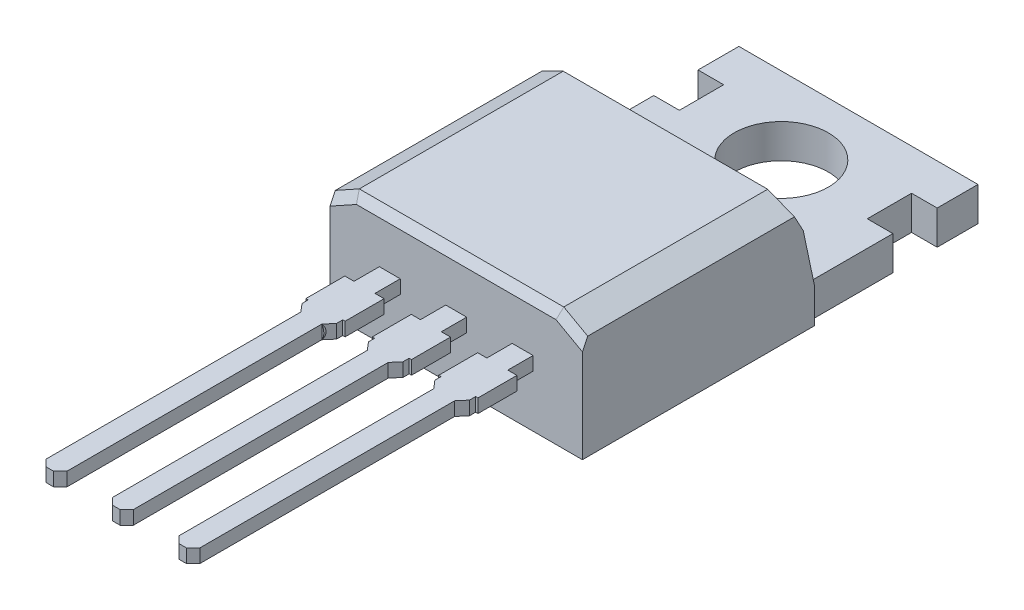
from build123d import *
from OCP.BRepFilletAPI import BRepFilletAPI_MakeChamfer

# Parameters (mm, degrees)
EXTRUDE1_DEPTH      = 4.826
EXTRUDE1_DEPTH_BACK = 4.826
SKETCH10_R          = 1.8
SKETCH10_W          = 1.233836604
SKETCH10_H          = 1.6931216
EXTRUDE5_DEPTH      = 16.428369203
SKETCH6_W           = 0.8
SKETCH6_H           = 0.52
EXTRUDE6_DEPTH      = 13
EXTRUDE7_START      = -0.52
EXTRUDE7_DEPTH      = 0.52
CHAMFER1_SIZE       = 0.254
SKETCH12_W          = 7.379682426
SKETCH12_H          = 2.736118788
EXTRUDE8_DEPTH      = 0.254
SKETCH13_W          = 7.379682426
SKETCH13_H          = 2.736118788
EXTRUDE9_DEPTH      = 0.254
CHAMFER2_SIZE       = 0.508
CHAMFER2_SIZE2      = 0.91645626
CHAMFER3_SIZE       = 0.2032
CHAMFER3_SIZE2      = 0.366582504
CHAMFER3_SIZE2_2    = 0.605677555
CHAMFER3_SIZE2_3    = 0.557834937
EXTRUDE10_DEPTH     = 1.016


with BuildPart() as part:
    # Sketch2 → Extrude1 (new, two sides)
    with BuildSketch(Plane(origin=(0, 0, 0), x_dir=(0, 0, -1), z_dir=(1, 0, 0))) as extrude1_sk:
        Polygon((14.3005, 0), (-1.0795, 0), (-1.0795, 4.5), (7.124012877, 4.5), (7.8005, 1.3), (14.3005, 1.3), align=None)
    extrude(amount=EXTRUDE1_DEPTH)
    extrude(extrude1_sk.sketch, amount=-EXTRUDE1_DEPTH_BACK)

    # Sketch10 → Extrude5 (cut, through all)
    with BuildSketch(Plane(origin=(0, 1.3, 0), x_dir=(1, 0, 0), z_dir=(0, 1, 0))):
        with Locations(Location((0, 11.3505, 0), (0, 0, 270))):
            Circle(SKETCH10_R)
        with Locations((-4.209081698, 11.892729701)):
            Rectangle(SKETCH10_W, SKETCH10_H)
        with Locations((4.209081698, 11.892729701)):
            Rectangle(SKETCH10_W, SKETCH10_H)
    extrude(amount=-EXTRUDE5_DEPTH, mode=Mode.SUBTRACT)

    # Sketch6 → Extrude6 (add)
    with BuildSketch(Plane.XY.offset(1.0795)):
        with Locations((2.54, 2.25)):
            Rectangle(SKETCH6_W, SKETCH6_H)
        with Locations((-2.54, 2.25)):
            Rectangle(SKETCH6_W, SKETCH6_H)
        with Locations((0, 2.25)):
            Rectangle(SKETCH6_W, SKETCH6_H)
    extrude(amount=EXTRUDE6_DEPTH)

    # Sketch11 → Extrude7 (add)
    with BuildSketch(Plane(origin=(0, 2.51, 0), x_dir=(1, 0, 0), z_dir=(0, 1, 0)).offset(EXTRUDE7_START)):
        Polygon((-2.94, -2.0475), (-3.29, -2.0475), (-3.29, -3.5395), (-3.2004, -3.5395), (-3.2004, -3.7747), (-2.94, -4.0795), align=None)
        Polygon((-1.79, -2.0475), (-2.14, -2.0475), (-2.14, -4.0795), (-1.8796, -3.7747), (-1.8796, -3.5395), (-1.79, -3.5395), align=None)
        Polygon((-0.4, -2.0475), (-0.75, -2.0475), (-0.75, -3.5395), (-0.6604, -3.5395), (-0.6604, -3.7747), (-0.4, -4.0795), align=None)
        Polygon((0.75, -2.0475), (0.4, -2.0475), (0.4, -4.0795), (0.6604, -3.7747), (0.6604, -3.5395), (0.75, -3.5395), align=None)
        Polygon((2.14, -2.0475), (1.79, -2.0475), (1.79, -3.5395), (1.8796, -3.5395), (1.8796, -3.7747), (2.14, -4.0795), align=None)
        Polygon((3.29, -2.0475), (2.94, -2.0475), (2.94, -4.0795), (3.2004, -3.7747), (3.2004, -3.5395), (3.29, -3.5395), align=None)
    extrude(amount=EXTRUDE7_DEPTH)

    # Chamfer1
    chamfer1_edges = [part.edges().sort_by_distance(p)[0] for p in [
        (-2.14, 2.25, 14.0795),
        (-2.94, 2.25, 14.0795),
        (2.94, 2.25, 14.0795),
        (2.14, 2.25, 14.0795),
        (0.4, 2.25, 14.0795),
        (-0.4, 2.25, 14.0795),
    ]]
    chamfer(chamfer1_edges, length=CHAMFER1_SIZE)

    # Sketch12 → Extrude8 (cut)
    with BuildSketch(Plane.ZY.offset(4.826)):
        with Locations((-11.490341213, 1.368059394)):
            Rectangle(SKETCH12_W, SKETCH12_H)
    extrude(amount=-EXTRUDE8_DEPTH, mode=Mode.SUBTRACT)

    # Sketch13 → Extrude9 (cut)
    with BuildSketch(Plane(origin=(4.826, 0, 0), x_dir=(0, 0, -1), z_dir=(1, 0, 0))):
        with Locations((11.490341213, 1.368059394)):
            Rectangle(SKETCH13_W, SKETCH13_H)
    extrude(amount=-EXTRUDE9_DEPTH, mode=Mode.SUBTRACT)

    # Chamfer2: one chamfer whose edges measure the first distance from different faces: ONE call of the kernel's chamfer builder (chamfer() names one face for all edges)
    chamfer2_edges_1 = [part.edges().sort_by_distance(p)[0] for p in [
        (-4.826, 4.5, -3.022256439),
    ]]
    chamfer2_side_1 = [part.faces().sort_by_distance(p)[0] for p in [
        (-4.826, 2.217055195, -3.243165334),
    ]]
    chamfer2_edges_2 = [part.edges().sort_by_distance(p)[0] for p in [
        (4.826, 4.5, -3.022256439),
    ]]
    chamfer2_side_2 = [part.faces().sort_by_distance(p)[0] for p in [
        (4.826, 2.217055195, -3.243165334),
    ]]
    chamfer2 = BRepFilletAPI_MakeChamfer(part.part.solid().wrapped)
    for e in chamfer2_edges_1:
        chamfer2.Add(CHAMFER2_SIZE, CHAMFER2_SIZE2, e.wrapped, chamfer2_side_1[0].wrapped)  # the first distance lies on this face
    for e in chamfer2_edges_2:
        chamfer2.Add(CHAMFER2_SIZE, CHAMFER2_SIZE2, e.wrapped, chamfer2_side_2[0].wrapped)  # the first distance lies on this face
    add(Compound.cast(chamfer2.Shape()), mode=Mode.REPLACE)

    # Chamfer3: one chamfer whose edges measure the first distance from different faces: ONE call of the kernel's chamfer builder (chamfer() names one face for all edges)
    chamfer3_edges_1 = [part.edges().sort_by_distance(p)[0] for p in [
        (0, 4.5, 1.0795),
    ]]
    chamfer3_side_1 = [part.faces().sort_by_distance(p)[0] for p in [
        (0, 4.5, -3.022256439),
    ]]
    chamfer3_edges_2 = [part.edges().sort_by_distance(p)[0] for p in [
        (-4.36777187, 4.246, 1.0795),
    ]]
    chamfer3_side_2 = [part.faces().sort_by_distance(p)[0] for p in [
        (-4.368765147, 4.245449417, -3.049162718),
    ]]
    chamfer3_edges_3 = [part.edges().sort_by_distance(p)[0] for p in [
        (4.36777187, 4.246, 1.0795),
    ]]
    chamfer3_side_3 = [part.faces().sort_by_distance(p)[0] for p in [
        (4.368765147, 4.245449417, -3.049162718),
    ]]
    chamfer3_edges_4 = [part.edges().sort_by_distance(p)[0] for p in [
        (0, 4.5, -7.124012877),
    ]]
    chamfer3_side_4 = [part.faces().sort_by_distance(p)[0] for p in [
        (0, 4.5, -3.022256439),
    ]]
    chamfer3_edges_5 = [part.edges().sort_by_distance(p)[0] for p in [
        (-4.36777187, 4.246, -7.177709043),
    ]]
    chamfer3_side_5 = [part.faces().sort_by_distance(p)[0] for p in [
        (-4.368765147, 4.245449417, -3.049162718),
    ]]
    chamfer3_edges_6 = [part.edges().sort_by_distance(p)[0] for p in [
        (4.36777187, 4.246, -7.177709043),
    ]]
    chamfer3_side_6 = [part.faces().sort_by_distance(p)[0] for p in [
        (4.368765147, 4.245449417, -3.049162718),
    ]]
    chamfer3 = BRepFilletAPI_MakeChamfer(part.part.solid().wrapped)
    for e in chamfer3_edges_1:
        chamfer3.Add(CHAMFER3_SIZE, CHAMFER3_SIZE2, e.wrapped, chamfer3_side_1[0].wrapped)  # the first distance lies on this face
    for e in chamfer3_edges_2:
        chamfer3.Add(CHAMFER3_SIZE, CHAMFER3_SIZE2, e.wrapped, chamfer3_side_2[0].wrapped)  # the first distance lies on this face
    for e in chamfer3_edges_3:
        chamfer3.Add(CHAMFER3_SIZE, CHAMFER3_SIZE2, e.wrapped, chamfer3_side_3[0].wrapped)  # the first distance lies on this face
    for e in chamfer3_edges_4:
        chamfer3.Add(CHAMFER3_SIZE, CHAMFER3_SIZE2_2, e.wrapped, chamfer3_side_4[0].wrapped)  # the first distance lies on this face
    for e in chamfer3_edges_5:
        chamfer3.Add(CHAMFER3_SIZE, CHAMFER3_SIZE2_3, e.wrapped, chamfer3_side_5[0].wrapped)  # the first distance lies on this face
    for e in chamfer3_edges_6:
        chamfer3.Add(CHAMFER3_SIZE, CHAMFER3_SIZE2_3, e.wrapped, chamfer3_side_6[0].wrapped)  # the first distance lies on this face
    add(Compound.cast(chamfer3.Shape()), mode=Mode.REPLACE)

    # Sketch15 → Extrude10 (add)
    with BuildSketch(Plane.XY.offset(4.0795)):
        with BuildLine():
            Line((-2.14, 2.51), (-2.94, 2.51))
            ThreePointArc((-2.94, 2.51), (-3.017074418, 2.25), (-2.94, 1.99))
            Line((-2.94, 1.99), (-2.14, 1.99))
            ThreePointArc((-2.14, 1.99), (-2.062925582, 2.25), (-2.14, 2.51))
        make_face()
    extrude(amount=-EXTRUDE10_DEPTH)


solid = part.part
